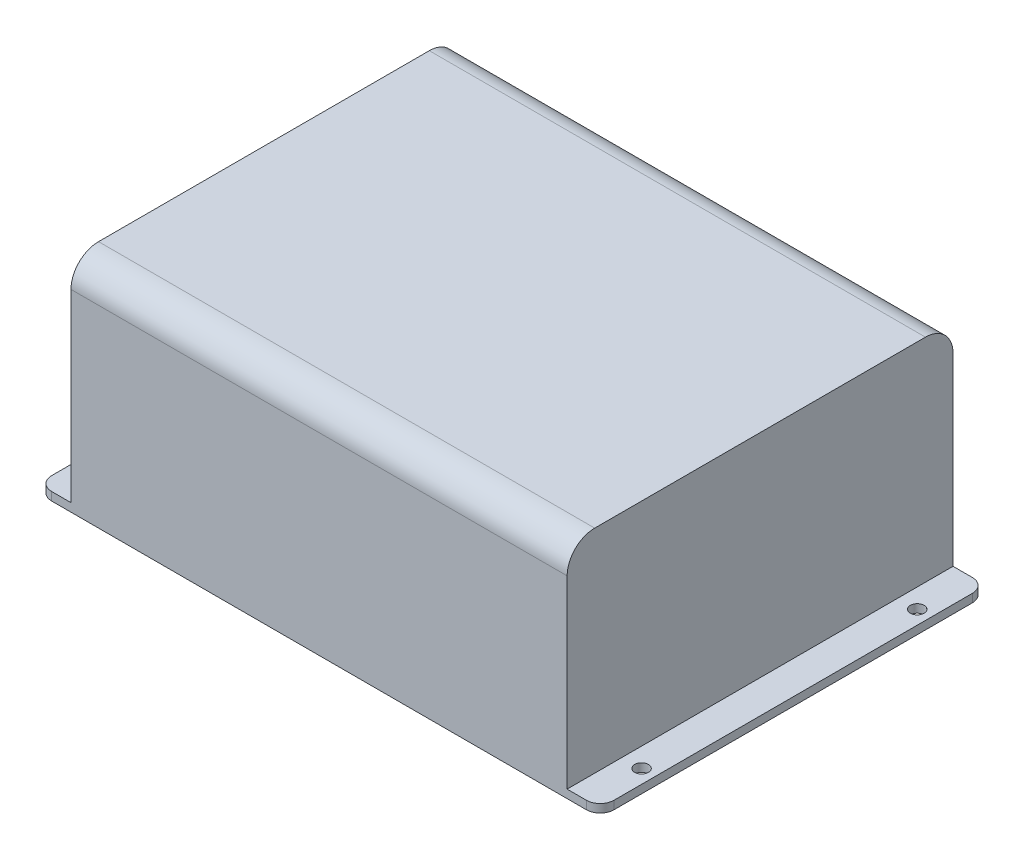
from build123d import *

# Parameters (mm, degrees)
CROQUIS1_W               = 180
CROQUIS1_H               = 140
SALIENTE_EXTRUIR1_DEPTH  = 80
CROQUIS2_W               = 12
CROQUIS2_H               = 140
SALIENTE_EXTRUIR2_DEPTH  = 3
REDONDEO1_R              = 5
CROQUIS3_R               = 2.5
CORTAR_EXTRUIR1_DEPTH    = 4
REDONDEO1_OF_SIMETR_A1_R = 5
REDONDEO2_R              = 10


with BuildPart() as part:
    # Croquis1 → Saliente-Extruir1 (new body)
    with BuildSketch(Plane(origin=(0, 0, 0), x_dir=(1, 0, 0), z_dir=(0, 1, 0))):
        Rectangle(CROQUIS1_W, CROQUIS1_H)
    extrude(amount=SALIENTE_EXTRUIR1_DEPTH)

    # Croquis2 → Saliente-Extruir2 (add)
    with BuildSketch(Plane.XZ):
        with Locations((96, 0)):
            Rectangle(CROQUIS2_W, CROQUIS2_H)
    saliente_extruir2 = extrude(amount=-SALIENTE_EXTRUIR2_DEPTH)

    # Redondeo1
    redondeo1_edges = [part.edges().sort_by_distance(p)[0] for p in [
        (102, 1.5, 70),
        (102, 1.5, -70),
    ]]
    fillet(redondeo1_edges, radius=REDONDEO1_R)

    # Croquis3 → Cortar-Extruir1 (cut, through all)
    with BuildSketch(Plane(origin=(0, 3, 0), x_dir=(1, 0, 0), z_dir=(0, 1, 0))):
        with Locations((97, 50)):
            Circle(CROQUIS3_R)
        with Locations((97, -50)):
            Circle(CROQUIS3_R)
    cortar_extruir1 = extrude(amount=-CORTAR_EXTRUIR1_DEPTH, mode=Mode.SUBTRACT)

    # Simetría1: Saliente-Extruir2, Cortar-Extruir1 across plane
    add(saliente_extruir2.mirror(Plane(origin=(0, 0, 0), x_dir=(0, 0, 1), z_dir=(1, 0, 0))))
    add(cortar_extruir1.mirror(Plane(origin=(0, 0, 0), x_dir=(0, 0, 1), z_dir=(1, 0, 0))), mode=Mode.SUBTRACT)

    # Redondeo1 of Simetría1
    redondeo1_of_simetr_a1_edges = [part.edges().sort_by_distance(p)[0] for p in [
        (-102, 1.5, 70),
        (-102, 1.5, -70),
    ]]
    fillet(redondeo1_of_simetr_a1_edges, radius=REDONDEO1_OF_SIMETR_A1_R)

    # Redondeo2
    redondeo2_edges = [part.edges().sort_by_distance(p)[0] for p in [
        (0, 80, 70),
        (0, 80, -70),
    ]]
    fillet(redondeo2_edges, radius=REDONDEO2_R)


solid = part.part
